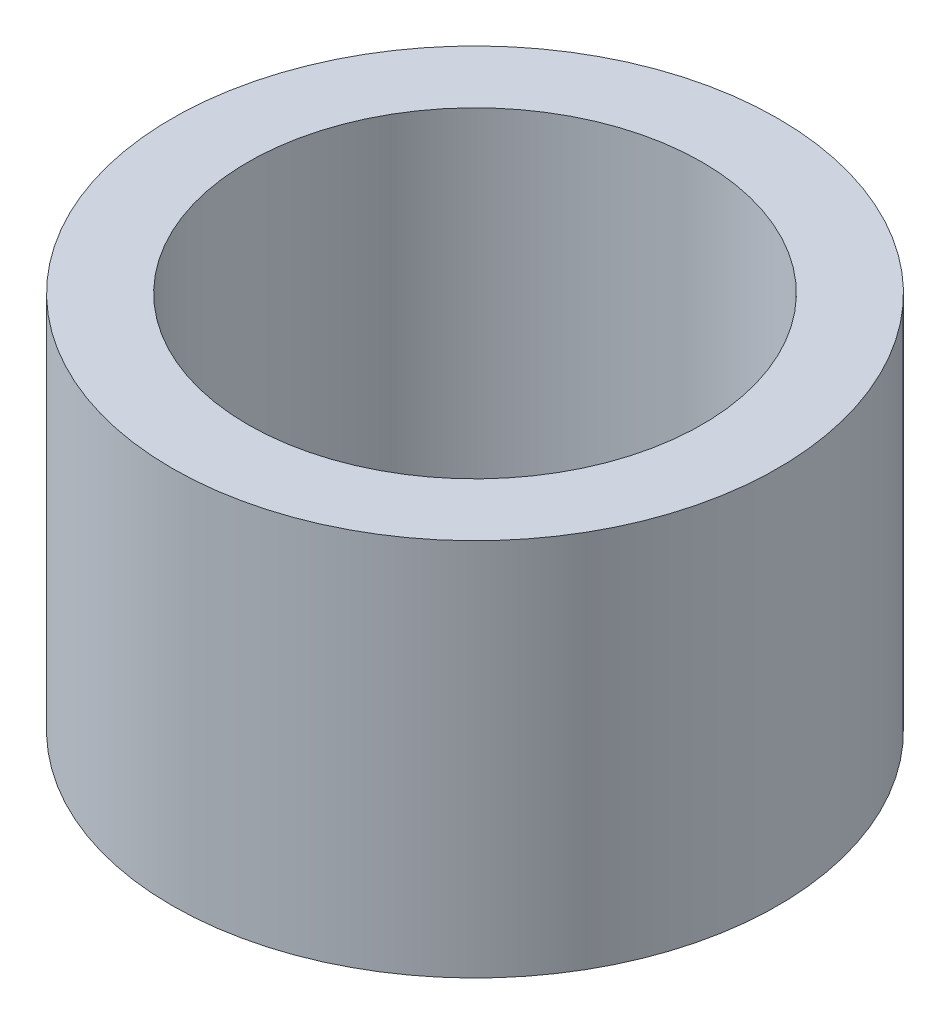
from build123d import *

# Parameters (mm, degrees)
SKETCH_1_R      = 8
SKETCH_1_R_2    = 6
EXTRUDE_1_DEPTH = 10


with BuildPart() as part:
    # ｽｹｯﾁ1 → ﾎﾞｽ - 押し出し1 (new body)
    with BuildSketch(Plane(origin=(0, 0, 0), x_dir=(1, 0, 0), z_dir=(0, 1, 0))):
        Circle(SKETCH_1_R)
        Circle(SKETCH_1_R_2, mode=Mode.SUBTRACT)
    extrude(amount=EXTRUDE_1_DEPTH)


solid = part.part
